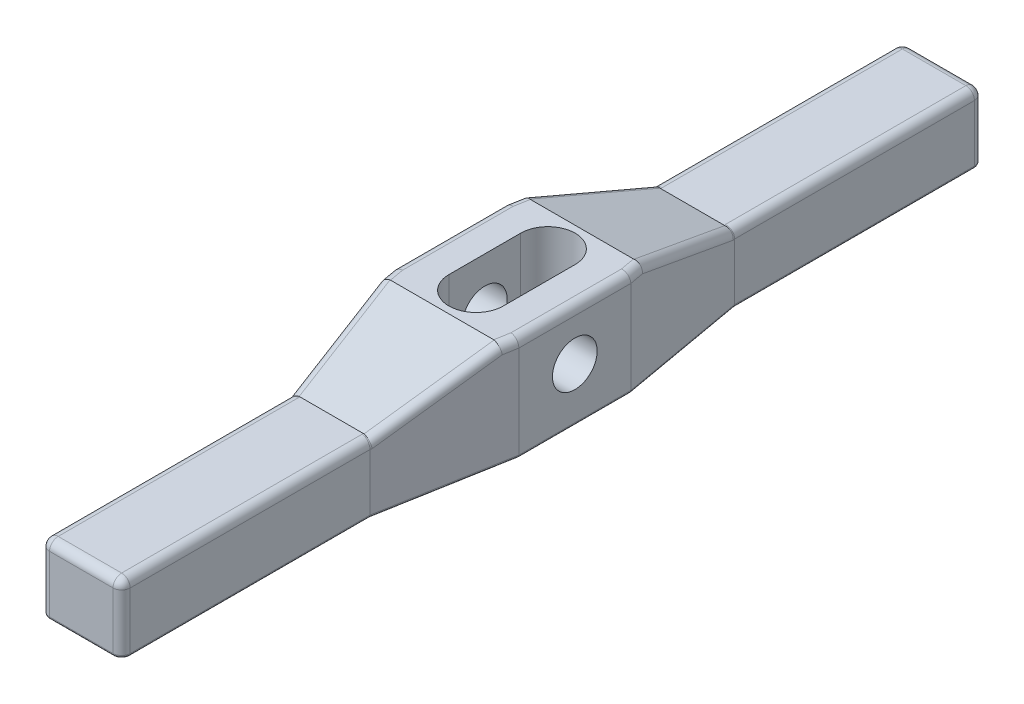
from build123d import *

# Parameters (mm, degrees)
EXTRUDE1_DEPTH     = 18.415
CUT_EXTRUDE1_DEPTH = 23.225
SKETCH3_R          = 3.95605
CUT_EXTRUDE2_DEPTH = 23.225
FILLET1_R          = 1.524
FILLET2_R          = 0.508
FILLET3_R          = 1.524


with BuildPart() as part:
    # Sketch1 → Extrude1 (new body)
    with BuildSketch(Plane(origin=(0, 0, 0), x_dir=(1, 0, 0), z_dir=(0, 1, 0))):
        Polygon((-7.1374, 76.2), (7.1374, 76.2), (7.1374, 32.258), (11.1125, 9.902952), (11.1125, -9.902952), (7.1374, -32.258), (7.1374, -76.2), (-7.1374, -76.2), (-7.1374, -32.258), (-11.1125, -9.902952), (-11.1125, 9.902952), (-7.1374, 32.258), align=None)
        with BuildLine():
            Line((-4.8133, 6.35), (-4.8133, -6.35))
            ThreePointArc((-4.8133, -6.35), (0, -11.1633), (4.8133, -6.35))
            Line((4.8133, -6.35), (4.8133, 6.35))
            ThreePointArc((4.8133, 6.35), (0, 11.1633), (-4.8133, 6.35))
        make_face(mode=Mode.SUBTRACT)
    extrude(amount=EXTRUDE1_DEPTH)

    # Sketch2 → Cut-Extrude1 (cut, through all)
    with BuildSketch(Plane(origin=(11.1125, 0, 0), x_dir=(0, 0, -1), z_dir=(1, 0, 0))):
        Polygon((76.2, 18.415), (12.3698, 18.415), (31.913090461, 12.065), (76.2, 12.065), align=None)
        Polygon((-76.2, 12.065), (-76.2, 18.415), (-12.3698, 18.415), (-31.913090461, 12.065), align=None)
    extrude(amount=-CUT_EXTRUDE1_DEPTH, mode=Mode.SUBTRACT)

    # Sketch3 → Cut-Extrude2 (cut, through all)
    with BuildSketch(Plane(origin=(11.1125, 0, 0), x_dir=(0, 0, -1), z_dir=(1, 0, 0))):
        with Locations((0, 9.525)):
            Circle(SKETCH3_R)
    extrude(amount=-CUT_EXTRUDE2_DEPTH, mode=Mode.SUBTRACT)

    # Fillet1
    fillet1_edges = [part.edges().sort_by_distance(p)[0] for p in [
        (-7.1374, 6.0325, -76.2),
        (7.1374, 6.0325, -76.2),
        (7.1374, 6.0325, 76.2),
        (-7.1374, 6.0325, 76.2),
    ]]
    fillet(fillet1_edges, radius=FILLET1_R)

    # Fillet2
    fillet2_edges = [part.edges().sort_by_distance(p)[0] for p in [
        (-7.1374, 0, -53.467),
        (7.1374, 0, 53.467),
        (0, 0, 76.2),
        (0, 0, -76.2),
        (-6.691030735, 0, 75.753630735),
        (9.12495, 0, -21.080476),
        (6.691030735, 0, 75.753630735),
        (6.691030735, 0, -75.753630735),
        (-6.691030735, 0, -75.753630735),
        (11.1125, 0, 0),
        (9.12495, 0, 21.080476),
        (-7.1374, 0, 53.467),
        (-9.12495, 0, 21.080476),
        (-11.1125, 0, 0),
        (-9.12495, 0, -21.080476),
        (7.1374, 0, -53.467),
    ]]
    fillet(fillet2_edges, radius=FILLET2_R)

    # Fillet3
    fillet3_edges = [part.edges().sort_by_distance(p)[0] for p in [
        (0, 12.065, -76.2),
        (7.1374, 12.065, -53.467),
        (6.691030735, 12.065, -75.753630735),
        (-6.691030735, 12.065, -75.753630735),
        (0, 12.065, 76.2),
        (-7.1374, 12.065, 53.467),
        (-6.691030735, 12.065, 75.753630735),
        (6.691030735, 12.065, 75.753630735),
        (-11.1125, 18.415, 0),
        (-10.893176662, 18.415, 11.136376),
        (11.1125, 18.415, 0),
        (10.893176662, 18.415, -11.136376),
        (8.936291994, 15.24, -22.141445231),
        (7.168065331, 12.065, -32.085545231),
        (-10.893176662, 18.415, -11.136376),
        (-7.168065331, 12.065, -32.085545231),
        (-7.1374, 12.065, -53.467),
        (-8.936291994, 15.24, -22.141445231),
        (10.893176662, 18.415, 11.136376),
        (8.936291994, 15.24, 22.141445231),
        (7.168065331, 12.065, 32.085545231),
        (-7.168065331, 12.065, 32.085545231),
        (7.1374, 12.065, 53.467),
        (-8.936291994, 15.24, 22.141445231),
    ]]
    fillet(fillet3_edges, radius=FILLET3_R)


solid = part.part
